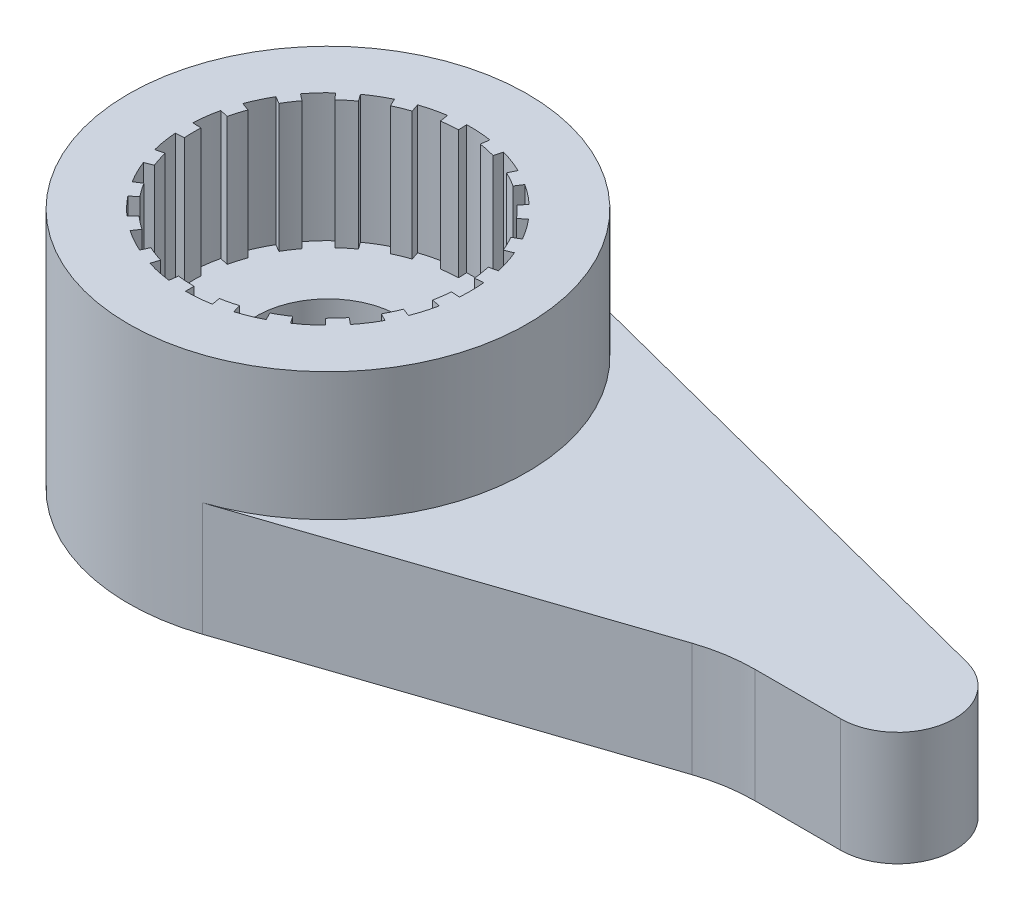
from build123d import *

# Parameters (mm, degrees)
SKETCH1_R           = 3.5
SKETCH1_R_2         = 2.5
BOSS_EXTRUDE1_DEPTH = 2.25
BOSS_EXTRUDE4_DEPTH = 2.25
BOSS_EXTRUDE2_START = 2.25
BOSS_EXTRUDE2_DEPTH = 2
SKETCH3_R           = 3.5
SKETCH3_R_2         = 1.25
BOSS_EXTRUDE3_DEPTH = 2
SKETCH4_R           = 2.25
CUT_EXTRUDE1_DEPTH  = 1.5


with BuildPart() as part:
    # Sketch1 → Boss-Extrude1 (new body)
    with BuildSketch(Plane(origin=(0, 0, 0), x_dir=(1, 0, 0), z_dir=(0, 1, 0))):
        Circle(SKETCH1_R)
        Circle(SKETCH1_R_2, mode=Mode.SUBTRACT)
    extrude(amount=BOSS_EXTRUDE1_DEPTH)

    # Sketch6 → Boss-Extrude4 (add)
    with BuildSketch(Plane.XZ):
        with BuildLine():
            Line((0.434120444, 2.462019383), (0.408073218, 2.31429822))
            ThreePointArc((0.408073218, 2.31429822), (0.551444891, 2.284383622), (0.69267466, 2.245596094))
            Line((0.69267466, 2.245596094), (0.736887936, 2.388932014))
            ThreePointArc((0.736887936, 2.388932014), (0.586643501, 2.430195342), (0.434120444, 2.462019383))
        make_face()
        with BuildLine():
            Line((1.140526643, 2.224679522), (1.072095045, 2.091198751))
            ThreePointArc((1.072095045, 2.091198751), (1.200279635, 2.020353632), (1.323802136, 1.94166112))
            Line((1.323802136, 1.94166112), (1.408300145, 2.065596936))
            ThreePointArc((1.408300145, 2.065596936), (1.276893228, 2.149312375), (1.140526643, 2.224679522))
        make_face()
        with BuildLine():
            Line((1.745592045, 1.789667123), (1.640856523, 1.682287096))
            ThreePointArc((1.640856523, 1.682287096), (1.742464265, 1.576806356), (1.837303984, 1.465201034))
            Line((1.837303984, 1.465201034), (1.954578706, 1.558724505))
            ThreePointArc((1.954578706, 1.558724505), (1.853685389, 1.67745357), (1.745592045, 1.789667123))
        make_face()
        with BuildLine():
            Line((2.195553933, 1.195634947), (2.063820697, 1.12389685))
            ThreePointArc((2.063820697, 1.12389685), (2.1298233, 0.993152915), (2.187553309, 0.858551407))
            Line((2.187553309, 0.858551407), (2.327184372, 0.913352561))
            ThreePointArc((2.327184372, 0.913352561), (2.265769468, 1.056545654), (2.195553933, 1.195634947))
        make_face()
        with BuildLine():
            Line((2.45043122, 0.495365358), (2.303405346, 0.465643437))
            ThreePointArc((2.303405346, 0.465643437), (2.327938187, 0.32125348), (2.343428923, 0.17561572))
            Line((2.343428923, 0.17561572), (2.493009493, 0.186825234))
            ThreePointArc((2.493009493, 0.186825234), (2.476529986, 0.341759021), (2.45043122, 0.495365358))
        make_face()
        with BuildLine():
            Line((2.487576938, -0.248919616), (2.338322322, -0.23398444))
            ThreePointArc((2.338322322, -0.23398444), (2.31920555, -0.379190737), (2.291080594, -0.522924195))
            Line((2.291080594, -0.522924195), (2.43731978, -0.556302335))
            ThreePointArc((2.43731978, -0.556302335), (2.467239947, -0.403394402), (2.487576938, -0.248919616))
        make_face()
        with BuildLine():
            Line((2.30369053, -0.971086991), (2.165469098, -0.912821771))
            ThreePointArc((2.165469098, -0.912821771), (2.104401323, -1.045942193), (2.035159699, -1.175))
            Line((2.035159699, -1.175), (2.165063509, -1.25))
            ThreePointArc((2.165063509, -1.25), (2.238724812, -1.112704461), (2.30369053, -0.971086991))
        make_face()
        with BuildLine():
            Line((1.915111108, -1.606969024), (1.800204441, -1.510550883))
            ThreePointArc((1.800204441, -1.510550883), (1.702611803, -1.619757095), (1.598405934, -1.722671899))
            Line((1.598405934, -1.722671899), (1.700431844, -1.83262968))
            ThreePointArc((1.700431844, -1.83262968), (1.811289152, -1.723145846), (1.915111108, -1.606969024))
        make_face()
        with BuildLine():
            Line((1.35636566, -2.100064808), (1.27498372, -1.974060919))
            ThreePointArc((1.27498372, -1.974060919), (1.149537753, -2.049649471), (1.019626787, -2.11727684))
            Line((1.019626787, -2.11727684), (1.084709348, -2.25242217))
            ThreePointArc((1.084709348, -2.25242217), (1.222912503, -2.180478161), (1.35636566, -2.100064808))
        make_face()
        with BuildLine():
            Line((0.67710117, -2.406560617), (0.6364751, -2.26216698))
            ThreePointArc((0.6364751, -2.26216698), (0.494322228, -2.297421497), (0.350249326, -2.323752442))
            Line((0.350249326, -2.323752442), (0.372605665, -2.472077066))
            ThreePointArc((0.372605665, -2.472077066), (0.525874711, -2.444065422), (0.67710117, -2.406560617))
        make_face()
        with BuildLine():
            Line((-0.062326729, -2.499222955), (-0.058587126, -2.349269578))
            ThreePointArc((-0.058587126, -2.349269578), (-0.204815995, -2.341057541), (-0.350249326, -2.323752442))
            Line((-0.350249326, -2.323752442), (-0.372605665, -2.472077066))
            ThreePointArc((-0.372605665, -2.472077066), (-0.217889357, -2.490486745), (-0.062326729, -2.499222955))
        make_face()
        with BuildLine():
            Line((-0.796216626, -2.369818365), (-0.748443628, -2.227629263))
            ThreePointArc((-0.748443628, -2.227629263), (-0.885755419, -2.176680348), (-1.019626787, -2.11727684))
            Line((-1.019626787, -2.11727684), (-1.084709348, -2.25242217))
            ThreePointArc((-1.084709348, -2.25242217), (-0.942292999, -2.315617392), (-0.796216626, -2.369818365))
        make_face()
        with BuildLine():
            Line((-1.459359181, -2.029845014), (-1.37179763, -1.908054313))
            ThreePointArc((-1.37179763, -1.908054313), (-1.487991587, -1.818895554), (-1.598405934, -1.722671899))
            Line((-1.598405934, -1.722671899), (-1.700431844, -1.83262968))
            ThreePointArc((-1.700431844, -1.83262968), (-1.582969773, -1.934995271), (-1.459359181, -2.029845014))
        make_face()
        with BuildLine():
            Line((-1.992831268, -1.509511026), (-1.873261392, -1.418940364))
            ThreePointArc((-1.873261392, -1.418940364), (-1.958013172, -1.299493909), (-2.035159699, -1.175))
            Line((-2.035159699, -1.175), (-2.165063509, -1.25))
            ThreePointArc((-2.165063509, -1.25), (-2.082992736, -1.382440328), (-1.992831268, -1.509511026))
        make_face()
        with BuildLine():
            Line((-2.349231552, -0.855050358), (-2.208277659, -0.803747337))
            ThreePointArc((-2.208277659, -0.803747337), (-2.254056694, -0.664626526), (-2.291080594, -0.522924195))
            Line((-2.291080594, -0.522924195), (-2.43731978, -0.556302335))
            ThreePointArc((-2.43731978, -0.556302335), (-2.397932653, -0.707049496), (-2.349231552, -0.855050358))
        make_face()
        with BuildLine():
            Line((-2.496892303, -0.124614714), (-2.347078765, -0.117137831))
            ThreePointArc((-2.347078765, -0.117137831), (-2.349817387, 0.029295839), (-2.343428923, 0.17561572))
            Line((-2.343428923, 0.17561572), (-2.493009493, 0.186825234))
            ThreePointArc((-2.493009493, 0.186825234), (-2.499805731, 0.031165786), (-2.496892303, -0.124614714))
        make_face()
        with BuildLine():
            Line((-2.422693216, 0.616893494), (-2.277331623, 0.579879885))
            ThreePointArc((-2.277331623, 0.579879885), (-2.236786494, 0.720615141), (-2.187553309, 0.858551407))
            Line((-2.187553309, 0.858551407), (-2.327184372, 0.913352561))
            ThreePointArc((-2.327184372, 0.913352561), (-2.3795601, 0.766611852), (-2.422693216, 0.616893494))
        make_face()
        with BuildLine():
            Line((-2.133227204, 1.303588008), (-2.005233572, 1.225372728))
            ThreePointArc((-2.005233572, 1.225372728), (-1.925007304, 1.347904625), (-1.837303984, 1.465201034))
            Line((-1.837303984, 1.465201034), (-1.954578706, 1.558724505))
            ThreePointArc((-1.954578706, 1.558724505), (-2.047880111, 1.433941091), (-2.133227204, 1.303588008))
        make_face()
        with BuildLine():
            Line((-1.654214594, 1.874453007), (-1.554961718, 1.761985827))
            ThreePointArc((-1.554961718, 1.761985827), (-1.442182768, 1.855426869), (-1.323802136, 1.94166112))
            Line((-1.323802136, 1.94166112), (-1.408300145, 2.065596936))
            ThreePointArc((-1.408300145, 2.065596936), (-1.534236987, 1.973858371), (-1.654214594, 1.874453007))
        make_face()
        with BuildLine():
            Line((-1.028217758, 2.278764631), (-0.966524692, 2.142038753))
            ThreePointArc((-0.966524692, 2.142038753), (-0.831213964, 2.198086292), (-0.69267466, 2.245596094))
            Line((-0.69267466, 2.245596094), (-0.736887936, 2.388932014))
            ThreePointArc((-0.736887936, 2.388932014), (-0.884270174, 2.338389672), (-1.028217758, 2.278764631))
        make_face()
        with BuildLine():
            Line((-0.310859262, 2.480598017), (-0.292207706, 2.331762136))
            ThreePointArc((-0.292207706, 2.331762136), (-0.146388151, 2.345436102), (0, 2.35))
            Line((0, 2.35), (0, 2.5))
            ThreePointArc((0, 2.5), (-0.155732076, 2.49514479), (-0.310859262, 2.480598017))
        make_face()
    extrude(amount=-BOSS_EXTRUDE4_DEPTH)



with BuildPart() as body_2:
    # Sketch2 → Boss-Extrude2 (new body)
    with BuildSketch(Plane(origin=(0, 0, 0), x_dir=(1, 0, 0), z_dir=(0, 1, 0)).offset(BOSS_EXTRUDE2_START)):
        with BuildLine():
            Line((10.25, 0.968245837), (0.875, 3.388860428))
            ThreePointArc((0.875, 3.388860428), (3.497755962, 0.12531253), (1.115267765, -3.317556))
            Line((1.115267765, -3.317556), (7.544056202, -1.156380571))
            ThreePointArc((7.544056202, -1.156380571), (8.015674844, -1.039353256), (8.5, -1))
            Line((8.5, -1), (10, -1))
            ThreePointArc((10, -1), (10.992029696, -0.126004292), (10.25, 0.968245837))
        make_face()
    extrude(amount=BOSS_EXTRUDE2_DEPTH)


with BuildPart() as part_1:
    add(part.part)

    add(body_2.part)  # Boss-Extrude3 merges body 2
    # Sketch3 → Boss-Extrude3 (add)
    with BuildSketch(Plane(origin=(0, 2.25, 0), x_dir=(1, 0, 0), z_dir=(0, 1, 0))):
        Circle(SKETCH3_R)
        Circle(SKETCH3_R_2, mode=Mode.SUBTRACT)
    extrude(amount=BOSS_EXTRUDE3_DEPTH)

    # Sketch4 → Cut-Extrude1 (cut)
    with BuildSketch(Plane(origin=(0, 4.25, 0), x_dir=(1, 0, 0), z_dir=(0, 1, 0))):
        Circle(SKETCH4_R)
    extrude(amount=-CUT_EXTRUDE1_DEPTH, mode=Mode.SUBTRACT)


with BuildPart() as body_2_2:
    # Mirror1: mirrored copy
    add(part_1.part.mirror(Plane(origin=(3.303845643, 4.25, -0.0910361), x_dir=(0, 0, 1), z_dir=(0, 1, 0))))


solid = body_2_2.part
